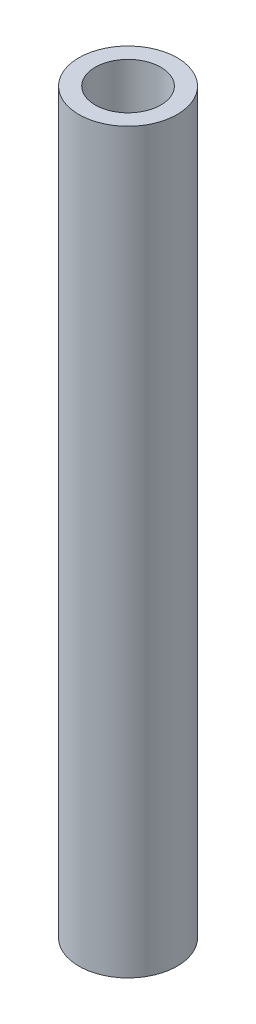
from build123d import *

# Parameters (mm, degrees)
SWEEP_THIN2_PROFILE_R   = 30
SWEEP_THIN2_PROFILE_R_2 = 20


with BuildPart() as part:
    # Sweep-Thin2: sweep along a path in Sketch1
    with BuildLine(Plane(origin=(0, 0, 0), x_dir=(0, 0, -1), z_dir=(1, 0, 0))) as sweep_thin2_path:
        Line((0, 0), (0, -450))
    # Sweep-Thin2 profile (on start of the path) → Sweep-Thin2 (sweep)
    with BuildSketch(Plane(origin=(0, 0, 0), x_dir=(0, 0, -1), z_dir=(0, -1, 0))):
        Circle(SWEEP_THIN2_PROFILE_R)
        Circle(SWEEP_THIN2_PROFILE_R_2, mode=Mode.SUBTRACT)
    sweep(path=sweep_thin2_path.line)


solid = part.part
